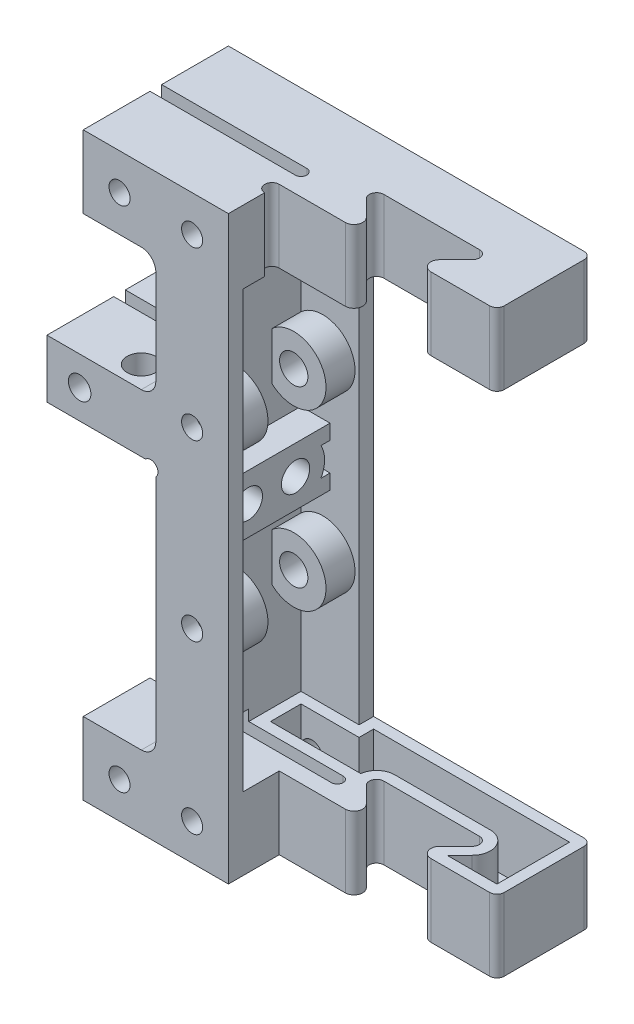
from build123d import *

# Parameters (mm, degrees)
SKETCH1_W                       = 20
SKETCH1_H                       = 10
BOSS_EXTRUDE1_DEPTH             = 10
M2_5_CLEARANCE_HOLE1_D          = 2.9
BOSS_EXTRUDE2_REACH             = 17
SKETCH6_W                       = 10
SKETCH6_H                       = 60
BOSS_EXTRUDE2_DIRECTION_2_REACH = 17
SKETCH4_W                       = 20
SKETCH4_H                       = 10
CUT_EXTRUDE1_DEPTH              = 0.8
CUT_EXTRUDE1_DEPTH_BACK         = 0.8
BOSS_EXTRUDE3_REACH             = 78.322
SKETCH7_W                       = 15
SKETCH7_H                       = 8
BOSS_EXTRUDE3_DIRECTION_2_REACH = 78.322
SKETCH8_W                       = 16
SKETCH8_H                       = 60
CUT_EXTRUDE3_DEPTH              = 8
SKETCH9_R                       = 1
CUT_EXTRUDE4_DEPTH              = 35
FILLET1_R                       = 2
SKETCH11_R                      = 1.95
CUT_EXTRUDE6_DEPTH              = 4
SKETCH12_R                      = 1.35
CUT_EXTRUDE7_DEPTH              = 9
SKETCH13_R                      = 1.35
CUT_EXTRUDE8_DEPTH              = 9
SKETCH14_R                      = 4
SKETCH14_R_2                    = 1.95
BOSS_EXTRUDE4_DEPTH             = 4
SKETCH15_W                      = 16
SKETCH15_H                      = 2.05
BOSS_EXTRUDE5_DEPTH             = 4
M2_5_CLEARANCE_HOLE2_D          = 2.9
SKETCH19_R                      = 4.45
SKETCH19_R_2                    = 1.95
BOSS_EXTRUDE6_DEPTH             = 4
MIRROR4_COPY_1_SKETCH_R         = 4.45
MIRROR4_COPY_1_SKETCH_R_2       = 1.95
MIRROR4_COPY_1_DEPTH            = 4
SKETCH20_W                      = 29.604642593
SKETCH20_H                      = 1.6
CUT_EXTRUDE9_DEPTH              = 128
M2_5_CLEARANCE_HOLE3_D          = 3.1
SKETCH24_W                      = 1.6
SKETCH24_H                      = 1.5
CUT_EXTRUDE10_DEPTH             = 20
BOSS_EXTRUDE7_DEPTH             = 10
FILLET2_R                       = 1
FILLET3_R                       = 1.2
SKETCH27_R                      = 0.8
SKETCH27_R_2                    = 1
CUT_EXTRUDE11_DEPTH             = 10
CUT_EXTRUDE12_DEPTH             = 8.5
FILLET2_OF_MIRROR5_R            = 1
FILLET3_OF_MIRROR5_R            = 1.2
SKETCH30_W                      = 5
SKETCH30_H                      = 1.6
CUT_EXTRUDE13_DEPTH             = 10.5
SKETCH31_R                      = 0.8
CUT_EXTRUDE14_DEPTH             = 10
CUT_EXTRUDE15_DEPTH             = 8.5


with BuildPart() as part:
    # Sketch1 → Boss-Extrude1 (new, symmetric)
    with BuildSketch(Plane.XY):
        Rectangle(SKETCH1_W, SKETCH1_H)
    boss_extrude1 = extrude(amount=BOSS_EXTRUDE1_DEPTH, both=True)

    # M2.5 Clearance Hole1 (through all)
    with Locations(Plane.XY.offset(10)):
        with Locations((-5, 0), (5, 0)):
            m2_5_clearance_hole1 = Hole(M2_5_CLEARANCE_HOLE1_D / 2)

    # Boss-Extrude2: up to this face of the body (flat: up to its plane)
    boss_extrude2_end = Plane(part.part.faces().sort_by_distance((0, 0, -10))[0])
    # Sketch6 → Boss-Extrude2 (add, up to the picked face)
    with BuildSketch(Plane.XY, mode=Mode.PRIVATE) as boss_extrude2_sk1:
        with Locations((5, -35)):
            Rectangle(SKETCH6_W, SKETCH6_H)
    boss_extrude2_tool1 = split(extrude(boss_extrude2_sk1.sketch, amount=-BOSS_EXTRUDE2_REACH, mode=Mode.PRIVATE), bisect_by=boss_extrude2_end, keep=Keep.BOTH, mode=Mode.PRIVATE)
    add(boss_extrude2_tool1.solids().sort_by(Axis((5, -35, 0), (0, 0, -1)))[0])

    # Boss-Extrude2 direction 2: up to this face of the body (flat: up to its plane)
    boss_extrude2_direction_2_end = Plane(part.part.faces().sort_by_distance((0, 0, 10))[0])
    # Sketch6 → Boss-Extrude2 direction 2 (add, up to the picked face)
    with BuildSketch(Plane.XY, mode=Mode.PRIVATE) as boss_extrude2_direction_2_sk1:
        with Locations((5, -35)):
            Rectangle(SKETCH6_W, SKETCH6_H)
    boss_extrude2_direction_2_tool1 = split(extrude(boss_extrude2_direction_2_sk1.sketch, amount=BOSS_EXTRUDE2_DIRECTION_2_REACH, mode=Mode.PRIVATE), bisect_by=boss_extrude2_direction_2_end, keep=Keep.BOTH, mode=Mode.PRIVATE)
    add(boss_extrude2_direction_2_tool1.solids().sort_by(Axis((5, -35, 0), (0, 0, 1)))[0])

    # Mirror1: Boss-Extrude1, M2.5 Clearance Hole1 across plane
    add(boss_extrude1.mirror(Plane(origin=(0, -35, 0), x_dir=(0, 0, 1), z_dir=(0, -1, 0))))
    add(m2_5_clearance_hole1.mirror(Plane(origin=(0, -35, 0), x_dir=(0, 0, 1), z_dir=(0, -1, 0))), mode=Mode.SUBTRACT)

    # Sketch4 → Cut-Extrude1 (cut, two sides)
    with BuildSketch(Plane.XY) as cut_extrude1_sk:
        Rectangle(SKETCH4_W, SKETCH4_H)
        with Locations((0, -70)):
            Rectangle(SKETCH4_W, SKETCH4_H)
    extrude(amount=CUT_EXTRUDE1_DEPTH, mode=Mode.SUBTRACT)
    extrude(cut_extrude1_sk.sketch, amount=-CUT_EXTRUDE1_DEPTH_BACK, mode=Mode.SUBTRACT)

    # Boss-Extrude3: up to this face of the body (flat: up to its plane)
    boss_extrude3_end = Plane(part.part.faces().sort_by_distance((3.081413389, -35, 10))[0])
    # Sketch7 → Boss-Extrude3 (add, up to the picked face)
    with BuildSketch(Plane.XY, mode=Mode.PRIVATE) as boss_extrude3_sk1:
        with Locations((-7.5, -26)):
            Rectangle(SKETCH7_W, SKETCH7_H)
    boss_extrude3_tool1 = split(extrude(boss_extrude3_sk1.sketch, amount=BOSS_EXTRUDE3_REACH, mode=Mode.PRIVATE), bisect_by=boss_extrude3_end, keep=Keep.BOTH, mode=Mode.PRIVATE)
    add(boss_extrude3_tool1.solids().sort_by(Axis((-7.5, -26, 0), (0, 0, 1)))[0])

    # Boss-Extrude3 direction 2: up to this face of the body (flat: up to its plane)
    boss_extrude3_direction_2_end = Plane(part.part.faces().sort_by_distance((3.081413389, -35, -10))[0])
    # Sketch7 → Boss-Extrude3 direction 2 (add, up to the picked face)
    with BuildSketch(Plane.XY, mode=Mode.PRIVATE) as boss_extrude3_direction_2_sk1:
        with Locations((-7.5, -26)):
            Rectangle(SKETCH7_W, SKETCH7_H)
    boss_extrude3_direction_2_tool1 = split(extrude(boss_extrude3_direction_2_sk1.sketch, amount=-BOSS_EXTRUDE3_DIRECTION_2_REACH, mode=Mode.PRIVATE), bisect_by=boss_extrude3_direction_2_end, keep=Keep.BOTH, mode=Mode.PRIVATE)
    add(boss_extrude3_direction_2_tool1.solids().sort_by(Axis((-7.5, -26, 0), (0, 0, -1)))[0])

    # Sketch8 → Cut-Extrude3 (cut)
    with BuildSketch(Plane(origin=(10, 0, 0), x_dir=(0, 0, -1), z_dir=(1, 0, 0))):
        with Locations((0, -35)):
            Rectangle(SKETCH8_W, SKETCH8_H)
    extrude(amount=-CUT_EXTRUDE3_DEPTH, mode=Mode.SUBTRACT)

    # Sketch9 → Cut-Extrude4 (cut)
    with BuildSketch(Plane.XY.offset(10)):
        with Locations((-0.707106781, -30.707106781)):
            Circle(SKETCH9_R)
    extrude(amount=-CUT_EXTRUDE4_DEPTH, mode=Mode.SUBTRACT)

    # Fillet1
    fillet1_edges = [part.edges().sort_by_distance(p)[0] for p in [
        (0, -65, 5.4),
        (0, -65, -5.4),
        (0, -5, -5.4),
        (0, -5, 5.4),
        (0, -22, 0),
    ]]
    fillet(fillet1_edges, radius=FILLET1_R)

    # Sketch11 → Cut-Extrude6 (cut)
    with BuildSketch(Plane(origin=(0, -22, 0), x_dir=(1, 0, 0), z_dir=(0, 1, 0))):
        with Locations(Location((-5, 7, 0), (0, 0, 270))):
            Circle(SKETCH11_R)
        with Locations(Location((-5, -7, 0), (0, 0, 270))):
            Circle(SKETCH11_R)
    extrude(amount=-CUT_EXTRUDE6_DEPTH, mode=Mode.SUBTRACT)

    # Sketch12 → Cut-Extrude7 (cut)
    with BuildSketch(Plane(origin=(0, -22, 0), x_dir=(1, 0, 0), z_dir=(0, 1, 0))):
        with Locations(Location((-5, 7, 0), (0, 0, 270))):
            Circle(SKETCH12_R)
        with Locations(Location((-5, -7, 0), (0, 0, 270))):
            Circle(SKETCH12_R)
    extrude(amount=-CUT_EXTRUDE7_DEPTH, mode=Mode.SUBTRACT)

    # Sketch13 → Cut-Extrude8 (cut)
    with BuildSketch(Plane.ZY):
        with Locations(Location((-3.25, -35, 0), (0, 0, 270))):
            Circle(SKETCH13_R)
        with Locations(Location((3.25, -35, 0), (0, 0, 270))):
            Circle(SKETCH13_R)
    extrude(amount=-CUT_EXTRUDE8_DEPTH, mode=Mode.SUBTRACT)

    # Sketch14 → Boss-Extrude4 (add)
    with BuildSketch(Plane(origin=(2, 0, 0), x_dir=(0, 0, -1), z_dir=(1, 0, 0))):
        with Locations((-3.25, -35)):
            Circle(SKETCH14_R)
        with Locations((-3.25, -35)):
            Circle(SKETCH14_R_2, mode=Mode.SUBTRACT)
    boss_extrude4 = extrude(amount=BOSS_EXTRUDE4_DEPTH)

    # Mirror2: Boss-Extrude4 across plane
    add(boss_extrude4.mirror(Plane.XY))

    # Sketch15 → Boss-Extrude5 (add)
    with BuildSketch(Plane(origin=(6, 0, 0), x_dir=(0, 0, -1), z_dir=(1, 0, 0))):
        with Locations((0, -32.025)):
            Rectangle(SKETCH15_W, SKETCH15_H)
        with Locations((0, -37.975)):
            Rectangle(SKETCH15_W, SKETCH15_H)
    extrude(amount=-BOSS_EXTRUDE5_DEPTH)

    # M2.5 Clearance Hole2 (through all)
    with Locations(Plane(origin=(0, 0, -10), x_dir=(-1, 0, 0), z_dir=(0, 0, -1))):
        with Locations((-5, -23), (-5, -47)):
            Hole(M2_5_CLEARANCE_HOLE2_D / 2)

    # Sketch19 → Boss-Extrude6 (add)
    with BuildSketch(Plane(origin=(0, 0, 8), x_dir=(-1, 0, 0), z_dir=(0, 0, -1))):
        with Locations((-5, -23)):
            Circle(SKETCH19_R)
        with Locations((-5, -23)):
            Circle(SKETCH19_R_2, mode=Mode.SUBTRACT)
    boss_extrude6 = extrude(amount=BOSS_EXTRUDE6_DEPTH)

    # Mirror3: Boss-Extrude6 across plane
    add(boss_extrude6.mirror(Plane.XY))

    # Mirror4: Boss-Extrude6 across plane
    add(boss_extrude6.mirror(Plane.ZX.offset(-35)))

    # Mirror4 copy 1 sketch → Mirror4 copy 1 (add)
    with BuildSketch(Plane(origin=(0, -70, -8), x_dir=(-1, 0, 0), z_dir=(0, 0, 1))):
        with Locations((-5, -23)):
            Circle(MIRROR4_COPY_1_SKETCH_R)
        with Locations((-5, -23)):
            Circle(MIRROR4_COPY_1_SKETCH_R_2, mode=Mode.SUBTRACT)
    extrude(amount=MIRROR4_COPY_1_DEPTH)

    # Sketch20 → Cut-Extrude9 (cut)
    with BuildSketch(Plane(origin=(0, 5, 0), x_dir=(1, 0, 0), z_dir=(0, 1, 0))):
        with Locations((-14.802321297, 0)):
            Rectangle(SKETCH20_W, SKETCH20_H)
    extrude(amount=-CUT_EXTRUDE9_DEPTH, mode=Mode.SUBTRACT)

    # M2.5 Clearance Hole3 (through all)
    with Locations(Plane.XY.offset(10)):
        with Locations((-10.5, -26)):
            Hole(M2_5_CLEARANCE_HOLE3_D / 2)

    # Sketch24 → Cut-Extrude10 (cut)
    with BuildSketch(Plane.ZY):
        with Locations((0, -5.75)):
            Rectangle(SKETCH24_W, SKETCH24_H)
        with Locations((0, -64.25)):
            Rectangle(SKETCH24_W, SKETCH24_H)
    extrude(amount=-CUT_EXTRUDE10_DEPTH, mode=Mode.SUBTRACT)

    # Sketch25 → Boss-Extrude7 (add)
    with BuildSketch(Plane(origin=(0, 5, 0), x_dir=(1, 0, 0), z_dir=(0, 1, 0))):
        Polygon((10, 10), (40, 10), (40, -3), (28, -3), (34, 3), (16, 3), (22, -3), (10, -3), align=None)
    boss_extrude7 = extrude(amount=-BOSS_EXTRUDE7_DEPTH)

    # Fillet2
    fillet2_edges = [part.edges().sort_by_distance(p)[0] for p in [
        (34, 0, -3),
        (16, 0, -3),
        (40, 0, -10),
        (40, 0, 3),
    ]]
    fillet(fillet2_edges, radius=FILLET2_R)

    # Fillet3
    fillet3_edges = [part.edges().sort_by_distance(p)[0] for p in [
        (28, 0, 3),
        (22, 0, 3),
    ]]
    fillet(fillet3_edges, radius=FILLET3_R)

    # Sketch27 → Cut-Extrude11 (cut)
    with BuildSketch(Plane(origin=(0, 5, 0), x_dir=(1, 0, 0), z_dir=(0, 1, 0))):
        with Locations((10, 0)):
            Circle(SKETCH27_R)
        with Locations((10, -4)):
            Circle(SKETCH27_R_2)
    extrude(amount=-CUT_EXTRUDE11_DEPTH, mode=Mode.SUBTRACT)

    # Sketch28 → Cut-Extrude12 (cut)
    with BuildSketch(Plane.XZ.offset(5)):
        with BuildLine():
            Line((18.378679656, 1.5), (11.743559577, 1.5))
            ThreePointArc((11.743559577, 1.5), (12.090454496, -0.959166305), (10, -2.3))
            Line((10, -2.3), (3.5, -2.3))
            Line((3.5, -2.3), (3.5, -6.5))
            Line((3.5, -6.5), (11.5, -6.5))
            Line((11.5, -6.5), (11.5, -8.5))
            Line((11.5, -8.5), (38.5, -8.5))
            Line((38.5, -8.5), (38.5, 1.5))
            Line((38.5, 1.5), (31.621320344, 1.5))
            Line((31.621320344, 1.5), (33.353553391, -0.232233047))
            ThreePointArc((33.353553391, -0.232233047), (33.895485269, -2.956708581), (31.585786438, -4.5))
            Line((31.585786438, -4.5), (18.414213562, -4.5))
            ThreePointArc((18.414213562, -4.5), (16.104514731, -2.956708581), (16.646446609, -0.232233047))
            Line((16.646446609, -0.232233047), (18.378679656, 1.5))
        make_face()
    extrude(amount=-CUT_EXTRUDE12_DEPTH, mode=Mode.SUBTRACT)

    # Mirror5: Boss-Extrude7 across plane
    add(boss_extrude7.mirror(Plane.ZX.offset(-35)))

    # Fillet2 of Mirror5
    fillet2_of_mirror5_edges = [part.edges().sort_by_distance(p)[0] for p in [
        (34, -70, -3),
        (16, -70, -3),
        (40, -70, -10),
        (40, -70, 3),
    ]]
    fillet(fillet2_of_mirror5_edges, radius=FILLET2_OF_MIRROR5_R)

    # Fillet3 of Mirror5
    fillet3_of_mirror5_edges = [part.edges().sort_by_distance(p)[0] for p in [
        (28, -70, 3),
        (22, -70, 3),
    ]]
    fillet(fillet3_of_mirror5_edges, radius=FILLET3_OF_MIRROR5_R)

    # Sketch30 → Cut-Extrude13 (cut)
    with BuildSketch(Plane.XZ.offset(75)):
        with Locations((12.5, 0)):
            Rectangle(SKETCH30_W, SKETCH30_H)
    extrude(amount=-CUT_EXTRUDE13_DEPTH, mode=Mode.SUBTRACT)

    # Sketch31 → Cut-Extrude14 (cut)
    with BuildSketch(Plane.XZ.offset(75)):
        with Locations((15, 0)):
            Circle(SKETCH31_R)
    extrude(amount=-CUT_EXTRUDE14_DEPTH, mode=Mode.SUBTRACT)

    # Sketch32 → Cut-Extrude15 (cut)
    with BuildSketch(Plane(origin=(0, -65, 0), x_dir=(1, 0, 0), z_dir=(0, 1, 0))):
        with BuildLine():
            Line((3.5, 2.3), (15.932278833, 2.3))
            ThreePointArc((15.932278833, 2.3), (16.755901167, 3.870828693), (18.414213562, 4.5))
            Line((18.414213562, 4.5), (31.585786438, 4.5))
            ThreePointArc((31.585786438, 4.5), (33.895485269, 2.956708581), (33.353553391, 0.232233047))
            Line((33.353553391, 0.232233047), (31.621320344, -1.5))
            Line((31.621320344, -1.5), (38.5, -1.5))
            Line((38.5, -1.5), (38.5, 8.5))
            Line((38.5, 8.5), (11.5, 8.5))
            Line((11.5, 8.5), (11.5, 6.5))
            Line((11.5, 6.5), (3.5, 6.5))
            Line((3.5, 6.5), (3.5, 2.3))
        make_face()
    extrude(amount=-CUT_EXTRUDE15_DEPTH, mode=Mode.SUBTRACT)


solid = part.part
